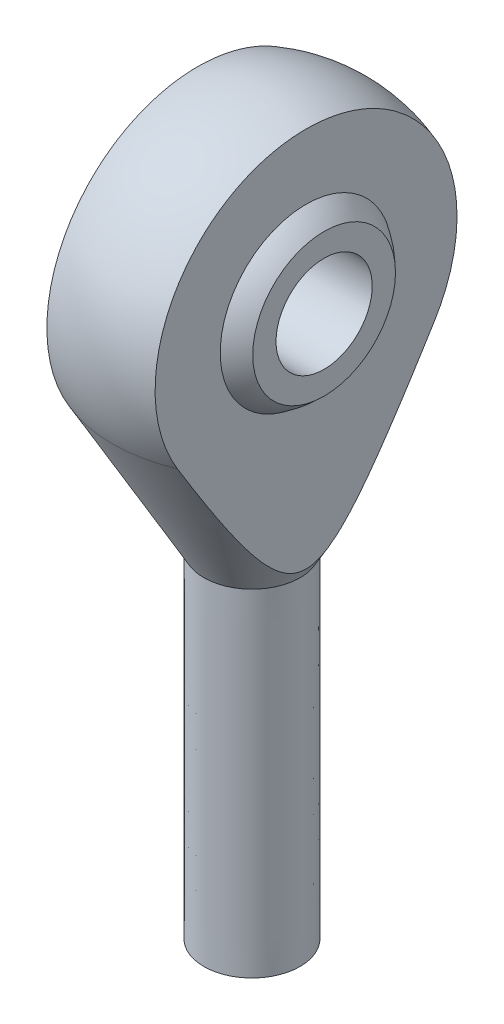
from build123d import *

# Parameters (mm, degrees)
WYTNIJ_WYCI_GNI_CIE1_DEPTH      = 10.998876849
WYTNIJ_WYCI_GNI_CIE1_DEPTH_BACK = 10.998876849
SZKIC4_W                        = 1.45
SZKIC4_H                        = 9
SZKIC8_R                        = 3
WYTNIJ_WYCI_GNI_CIE3_DEPTH      = 5.5
WYTNIJ_WYCI_GNI_CIE3_DEPTH_BACK = 5.5


with BuildPart() as part:
    # Szkic1 one side → Obrót4 (revolve)
    with BuildSketch(Plane.XY):
        with BuildLine():
            Line((-3, 21), (-3, 0))
            Line((-3, 0), (0, 0))
            Line((0, 0), (0.005166955, 46))
            ThreePointArc((0.005166955, 46), (-8.632770826, 41.038455208), (-8.699205566, 31.077206177))
            Line((-8.699205566, 31.077206177), (-3, 21))
        make_face()
    revolve(axis=Axis((0.005166955, 46, 0), (-0.000112325, -0.999999994, 0)))

    # Szkic2 → Wytnij-wyciągnięcie1 (cut, two sides)
    with BuildSketch(Plane.XY) as wytnij_wyci_gni_cie1_sk:
        Polygon((-3.375, 46), (-20, 46), (-20, 10.866665268), (-3.375, 21.663066505), align=None)
        Polygon((20, 46), (3.375, 46), (3.375, 21.65370739), (20, 10.857306153), align=None)
    extrude(amount=WYTNIJ_WYCI_GNI_CIE1_DEPTH, mode=Mode.SUBTRACT)
    extrude(wytnij_wyci_gni_cie1_sk.sketch, amount=-WYTNIJ_WYCI_GNI_CIE1_DEPTH_BACK, mode=Mode.SUBTRACT)

    # Szkic4 → Obrót5 (revolve)
    with BuildSketch(Plane.YX):
        with BuildLine():
            Line((40.449326049, 4.5), (40.449326049, -4.5))
            ThreePointArc((40.449326049, -4.5), (41.839498769, -2.438212993), (42.328030498, 0))
            ThreePointArc((42.328030498, 0), (41.839498769, 2.438212993), (40.449326049, 4.5))
        make_face()
        with Locations((39.724326049, 0)):
            Rectangle(SZKIC4_W, SZKIC4_H)
    revolve(axis=Axis((-0.999999975, 35.999326049, 0), (1, 0, 0)))

    # Szkic8 → Wytnij-wyciągnięcie3 (cut, two sides)
    with BuildSketch(Plane(origin=(0, 0, 0), x_dir=(0, 0, -1), z_dir=(1, 0, 0))) as wytnij_wyci_gni_cie3_sk:
        with Locations((0, 35.999326049)):
            Circle(SZKIC8_R)
    extrude(amount=WYTNIJ_WYCI_GNI_CIE3_DEPTH, mode=Mode.SUBTRACT)
    extrude(wytnij_wyci_gni_cie3_sk.sketch, amount=-WYTNIJ_WYCI_GNI_CIE3_DEPTH_BACK, mode=Mode.SUBTRACT)


solid = part.part
